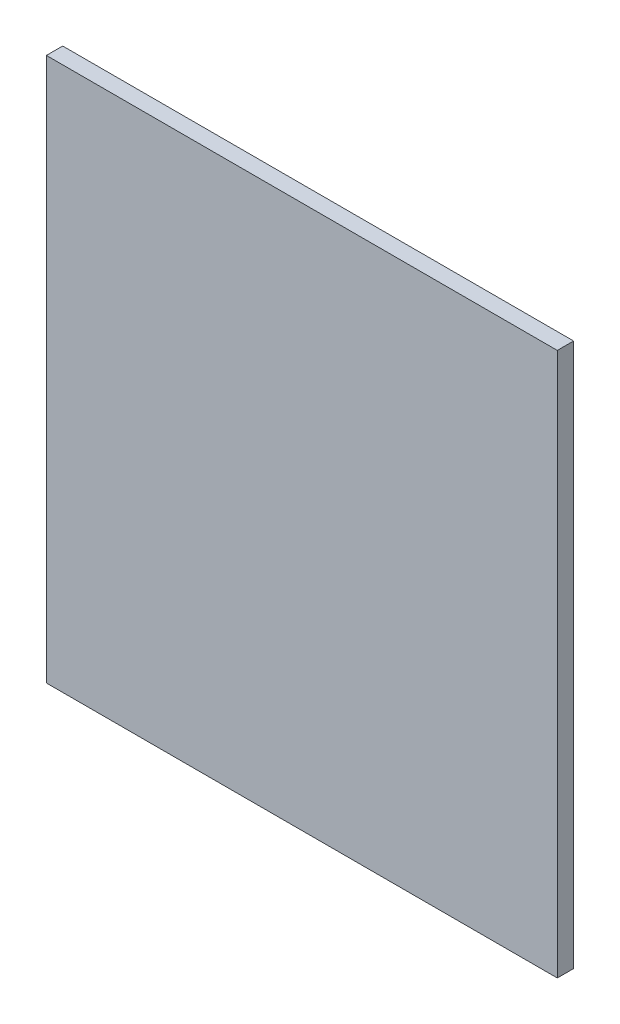
from build123d import *

# Parameters (mm, degrees)
SKETCH1_W           = 564
SKETCH1_H           = 600
BOSS_EXTRUDE1_DEPTH = 18


with BuildPart() as part:
    # Sketch1 → Boss-Extrude1 (new body)
    with BuildSketch(Plane.XY):
        Rectangle(SKETCH1_W, SKETCH1_H)
    extrude(amount=BOSS_EXTRUDE1_DEPTH)


solid = part.part
